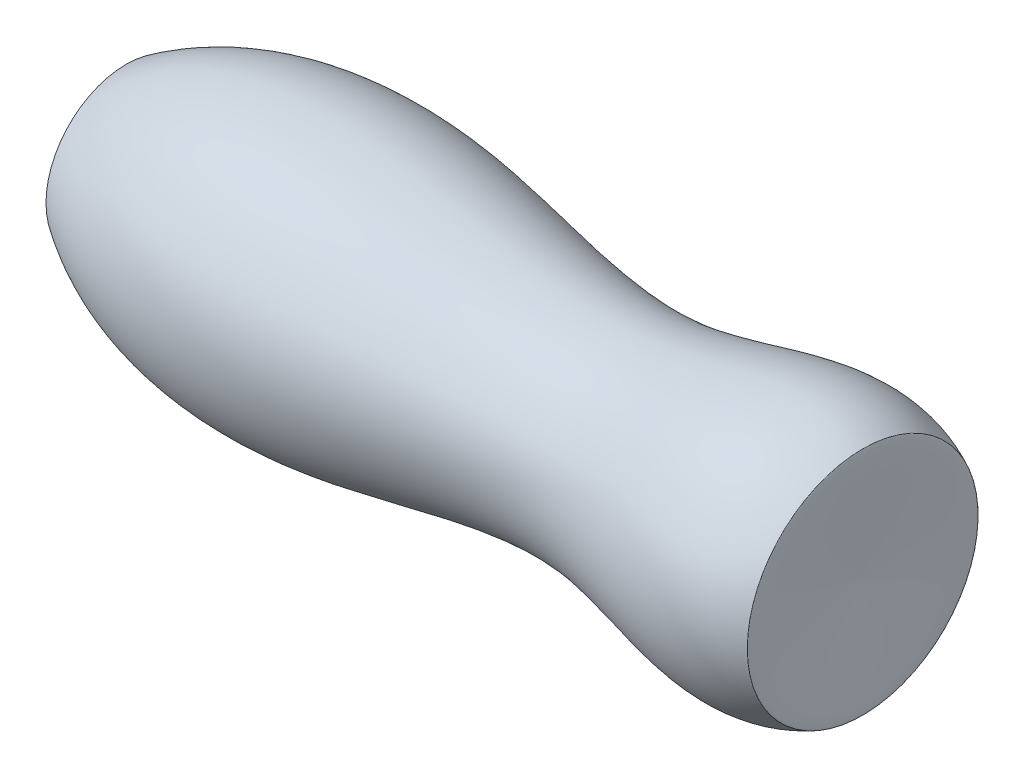
from build123d import *


with BuildPart() as part:
    # Croquis1 → Revolución2 (revolve)
    with BuildSketch(Plane.XY):
        with BuildLine():
            Line((-68.046566999, -9.165887628), (133.229945558, -9.165887628))
            add(Edge.make_bspline(
                [(134.3631987, 22.796343468), (134.948752986, 22.61113893), (133.789640715, 4.979713919), (133.229945558, -9.165887628)],
                knots=[0, 0, 0, 0, 0.459527671, 0.459527671, 0.459527671, 0.459527671], degree=3))
            add(Edge.make_bspline(
                [(-69.650770075, 13.039153657), (-48.219054364, 27.596512469), (2.253454013, 32.909097965), (70.615140869, 9.186875236), (114.229831827, 32.542935107), (134.3631987, 22.796343468)],
                knots=[0, 0, 0, 0, 0.362659631, 0.70231807, 1, 1, 1, 1], degree=3))
            add(Edge.make_bspline(
                [(-69.650770075, 13.039153657), (-68.849907518, 5.647119783), (-68.31517311, -1.754562006), (-68.046566999, -9.165887628)],
                knots=[0, 0, 0, 0, 0.495387551, 0.495387551, 0.495387551, 0.495387551], degree=3))
        make_face()
    revolve(axis=Axis((-68.046566999, -9.165887628, 0), (1, 0, 0)))


solid = part.part
